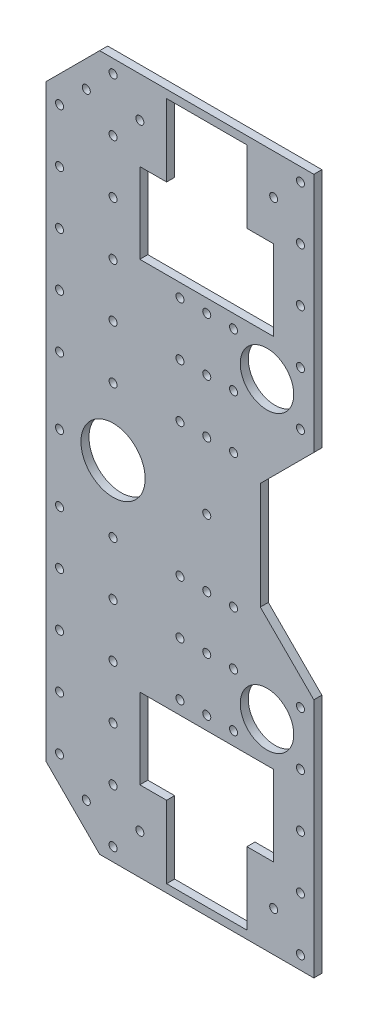
from build123d import *

# Parameters (mm, degrees)
MAIN_DEPTH                    = 3
MOTORCODERLEFTHOLE_DEPTH      = 144.209636547
SKETCH4_R                     = 1.5
BOTTOMLEFTHOLE_DEPTH          = 144.209636547
BOTTOMLEFTHOLELPATTERN_COUNT  = 5
BOTTOMLEFTHOLELPATTERN_PITCH  = 20
SKETCH5_R                     = 1.5
BOTTOMLEFTHOLE2_DEPTH         = 144.209636547
BOTTOMLEFTHOLE2LPATTERN_COUNT = 6
BOTTOMLEFTHOLE2LPATTERN_PITCH = 20
SKETCH6_R                     = 1.5
TOPLEFTHOLE_DEPTH             = 144.209636547
TOPLEFTHOLELPATTERN_COUNT     = 5
TOPLEFTHOLELPATTERN_PITCH     = 20
SKETCH7_R                     = 1.5
MOTORFIXHOLES_DEPTH           = 144.209636547
MOTORFIXHOLELPATTERN_COUNT    = 3
MOTORFIXHOLELPATTERN_PITCH    = 20
SKETCH8_R                     = 1.5
CODERHOLE_DEPTH               = 144.209636547
MIRROR1_COPY_1_SKETCH_R       = 1.5
MIRROR1_COPY_1_DEPTH          = 144.209636547
MIRROR1_COPY_2_SKETCH_R       = 1.5
MIRROR1_COPY_2_DEPTH          = 144.209636547
MIRROR1_COPY_3_SKETCH_R       = 1.5
MIRROR1_COPY_3_DEPTH          = 144.209636547
MIRROR1_COPY_4_SKETCH_R       = 1.5
MIRROR1_COPY_4_DEPTH          = 144.209636547
MIRROR1_COPY_5_SKETCH_R       = 1.5
MIRROR1_COPY_5_DEPTH          = 144.209636547
MIRROR1_COPY_6_SKETCH_R       = 1.5
MIRROR1_COPY_6_DEPTH          = 144.209636547
MIRROR1_COPY_7_SKETCH_R       = 1.5
MIRROR1_COPY_7_DEPTH          = 144.209636547
MIRROR1_COPY_8_SKETCH_R       = 1.5
MIRROR1_COPY_8_DEPTH          = 144.209636547
MIRROR1_COPY_9_SKETCH_R       = 1.5
MIRROR1_COPY_9_DEPTH          = 144.209636547
MIRROR1_COPY_10_SKETCH_R      = 1.5
MIRROR1_COPY_10_DEPTH         = 144.209636547
MIRROR1_COPY_11_SKETCH_R      = 1.5
MIRROR1_COPY_11_DEPTH         = 144.209636547
MIRROR1_COPY_12_SKETCH_R      = 1.5
MIRROR1_COPY_12_DEPTH         = 144.209636547
MIRROR1_COPY_13_SKETCH_R      = 1.5
MIRROR1_COPY_13_DEPTH         = 144.209636547
MIRROR1_COPY_14_SKETCH_R      = 1.5
MIRROR1_COPY_14_DEPTH         = 144.209636547
MIRROR1_COPY_15_SKETCH_R      = 1.5
MIRROR1_COPY_15_DEPTH         = 144.209636547
MIRROR1_COPY_16_SKETCH_R      = 1.5
MIRROR1_COPY_16_DEPTH         = 144.209636547
MIRROR1_COPY_17_SKETCH_R      = 1.5
MIRROR1_COPY_17_DEPTH         = 144.209636547
MIRROR1_COPY_18_SKETCH_R      = 1.5
MIRROR1_COPY_18_DEPTH         = 144.209636547
MIRROR1_COPY_19_SKETCH_R      = 1.5
MIRROR1_COPY_19_DEPTH         = 144.209636547
SKETCH3_R                     = 12
SKETCH3_R_2                   = 10
SKETCH3_R_3                   = 1.5
BIGHOLES_DEPTH                = 144.209636547


with BuildPart() as part:
    # Sketch1 → Main (new body)
    with BuildSketch(Plane.XY):
        Polygon((-60, 110), (-60, -110), (-40, -130), (40, -130), (40, -40), (20, -20), (20, 20), (40, 40), (40, 130), (-40, 130), align=None)
    extrude(amount=MAIN_DEPTH)

    # Sketch2 → MotorCoderLeftHole (cut, through all)
    with BuildSketch(Plane.XY.offset(3)):
        Polygon((-25, 100), (-25, 70), (25, 70), (25, 100), (15, 100), (15, 127), (-15, 127), (-15, 100), align=None)
    motorcoderlefthole = extrude(amount=-MOTORCODERLEFTHOLE_DEPTH, mode=Mode.SUBTRACT)

    # Sketch4 → BottomLeftHole (cut, through all)
    with BuildSketch(Plane.XY.offset(3)):
        with Locations((-55, 105)):
            Circle(SKETCH4_R)
    bottomlefthole = extrude(amount=-BOTTOMLEFTHOLE_DEPTH, mode=Mode.SUBTRACT)

    # BottomLeftHoleLPattern: BottomLeftHole ×5
    with Locations(*[(0, -i * BOTTOMLEFTHOLELPATTERN_PITCH, 0) for i in range(1, BOTTOMLEFTHOLELPATTERN_COUNT)]):
        add(bottomlefthole, mode=Mode.SUBTRACT)

    # Sketch5 → BottomLeftHole2 (cut, through all)
    with BuildSketch(Plane.XY.offset(3)):
        with Locations((-35, 125)):
            Circle(SKETCH5_R)
    bottomlefthole2 = extrude(amount=-BOTTOMLEFTHOLE2_DEPTH, mode=Mode.SUBTRACT)

    # BottomLeftHole2LPattern: BottomLeftHole2 ×6
    with Locations(*[(0, -i * BOTTOMLEFTHOLE2LPATTERN_PITCH, 0) for i in range(1, BOTTOMLEFTHOLE2LPATTERN_COUNT)]):
        add(bottomlefthole2, mode=Mode.SUBTRACT)

    # Sketch6 → TopLeftHole (cut, through all)
    with BuildSketch(Plane.XY.offset(3)):
        with Locations((35, 125)):
            Circle(SKETCH6_R)
    toplefthole = extrude(amount=-TOPLEFTHOLE_DEPTH, mode=Mode.SUBTRACT)

    # TopLeftHoleLPattern: TopLeftHole ×5
    with Locations(*[(0, -i * TOPLEFTHOLELPATTERN_PITCH, 0) for i in range(1, TOPLEFTHOLELPATTERN_COUNT)]):
        add(toplefthole, mode=Mode.SUBTRACT)

    # Sketch7 → MotorFixHoles (cut, through all)
    with BuildSketch(Plane.XY.offset(3)):
        with Locations((0, 65)):
            Circle(SKETCH7_R)
        with Locations((-10, 65)):
            Circle(SKETCH7_R)
        with Locations((10, 65)):
            Circle(SKETCH7_R)
    motorfixholes = extrude(amount=-MOTORFIXHOLES_DEPTH, mode=Mode.SUBTRACT)

    # MotorFixHoleLPattern: MotorFixHoles ×3
    with Locations(*[(0, -i * MOTORFIXHOLELPATTERN_PITCH, 0) for i in range(1, MOTORFIXHOLELPATTERN_COUNT)]):
        add(motorfixholes, mode=Mode.SUBTRACT)

    # Sketch8 → CoderHole (cut, through all)
    with BuildSketch(Plane.XY.offset(3)):
        with Locations((-45, 115)):
            Circle(SKETCH8_R)
        with Locations((-25, 115)):
            Circle(SKETCH8_R)
        with Locations((25, 115)):
            Circle(SKETCH8_R)
    coderhole = extrude(amount=-CODERHOLE_DEPTH, mode=Mode.SUBTRACT)

    # Mirror1: MotorCoderLeftHole, CoderHole across plane
    add(motorcoderlefthole.mirror(Plane.ZX), mode=Mode.SUBTRACT)
    add(coderhole.mirror(Plane.ZX), mode=Mode.SUBTRACT)

    # Mirror1 copy 1 sketch → Mirror1 copy 1 (cut, through all)
    with BuildSketch(Plane(origin=(0, 20, 3), x_dir=(1, 0, 0), z_dir=(0, 0, 1))):
        with Locations((-55, -105)):
            Circle(MIRROR1_COPY_1_SKETCH_R)
    extrude(amount=-MIRROR1_COPY_1_DEPTH, mode=Mode.SUBTRACT)

    # Mirror1 copy 2 sketch → Mirror1 copy 2 (cut, through all)
    with BuildSketch(Plane(origin=(0, 40, 3), x_dir=(1, 0, 0), z_dir=(0, 0, 1))):
        with Locations((-55, -105)):
            Circle(MIRROR1_COPY_2_SKETCH_R)
    extrude(amount=-MIRROR1_COPY_2_DEPTH, mode=Mode.SUBTRACT)

    # Mirror1 copy 3 sketch → Mirror1 copy 3 (cut, through all)
    with BuildSketch(Plane(origin=(0, 60, 3), x_dir=(1, 0, 0), z_dir=(0, 0, 1))):
        with Locations((-55, -105)):
            Circle(MIRROR1_COPY_3_SKETCH_R)
    extrude(amount=-MIRROR1_COPY_3_DEPTH, mode=Mode.SUBTRACT)

    # Mirror1 copy 4 sketch → Mirror1 copy 4 (cut, through all)
    with BuildSketch(Plane(origin=(0, 80, 3), x_dir=(1, 0, 0), z_dir=(0, 0, 1))):
        with Locations((-55, -105)):
            Circle(MIRROR1_COPY_4_SKETCH_R)
    extrude(amount=-MIRROR1_COPY_4_DEPTH, mode=Mode.SUBTRACT)

    # Mirror1 copy 5 sketch → Mirror1 copy 5 (cut, through all)
    with BuildSketch(Plane.XY.offset(3)):
        with Locations((-55, -105)):
            Circle(MIRROR1_COPY_5_SKETCH_R)
    extrude(amount=-MIRROR1_COPY_5_DEPTH, mode=Mode.SUBTRACT)

    # Mirror1 copy 6 sketch → Mirror1 copy 6 (cut, through all)
    with BuildSketch(Plane(origin=(0, 20, 3), x_dir=(1, 0, 0), z_dir=(0, 0, 1))):
        with Locations((-35, -125)):
            Circle(MIRROR1_COPY_6_SKETCH_R)
    extrude(amount=-MIRROR1_COPY_6_DEPTH, mode=Mode.SUBTRACT)

    # Mirror1 copy 7 sketch → Mirror1 copy 7 (cut, through all)
    with BuildSketch(Plane(origin=(0, 40, 3), x_dir=(1, 0, 0), z_dir=(0, 0, 1))):
        with Locations((-35, -125)):
            Circle(MIRROR1_COPY_7_SKETCH_R)
    extrude(amount=-MIRROR1_COPY_7_DEPTH, mode=Mode.SUBTRACT)

    # Mirror1 copy 8 sketch → Mirror1 copy 8 (cut, through all)
    with BuildSketch(Plane(origin=(0, 60, 3), x_dir=(1, 0, 0), z_dir=(0, 0, 1))):
        with Locations((-35, -125)):
            Circle(MIRROR1_COPY_8_SKETCH_R)
    extrude(amount=-MIRROR1_COPY_8_DEPTH, mode=Mode.SUBTRACT)

    # Mirror1 copy 9 sketch → Mirror1 copy 9 (cut, through all)
    with BuildSketch(Plane(origin=(0, 80, 3), x_dir=(1, 0, 0), z_dir=(0, 0, 1))):
        with Locations((-35, -125)):
            Circle(MIRROR1_COPY_9_SKETCH_R)
    extrude(amount=-MIRROR1_COPY_9_DEPTH, mode=Mode.SUBTRACT)

    # Mirror1 copy 10 sketch → Mirror1 copy 10 (cut, through all)
    with BuildSketch(Plane(origin=(0, 100, 3), x_dir=(1, 0, 0), z_dir=(0, 0, 1))):
        with Locations((-35, -125)):
            Circle(MIRROR1_COPY_10_SKETCH_R)
    extrude(amount=-MIRROR1_COPY_10_DEPTH, mode=Mode.SUBTRACT)

    # Mirror1 copy 11 sketch → Mirror1 copy 11 (cut, through all)
    with BuildSketch(Plane.XY.offset(3)):
        with Locations((-35, -125)):
            Circle(MIRROR1_COPY_11_SKETCH_R)
    extrude(amount=-MIRROR1_COPY_11_DEPTH, mode=Mode.SUBTRACT)

    # Mirror1 copy 12 sketch → Mirror1 copy 12 (cut, through all)
    with BuildSketch(Plane(origin=(0, 20, 3), x_dir=(1, 0, 0), z_dir=(0, 0, 1))):
        with Locations((35, -125)):
            Circle(MIRROR1_COPY_12_SKETCH_R)
    extrude(amount=-MIRROR1_COPY_12_DEPTH, mode=Mode.SUBTRACT)

    # Mirror1 copy 13 sketch → Mirror1 copy 13 (cut, through all)
    with BuildSketch(Plane(origin=(0, 40, 3), x_dir=(1, 0, 0), z_dir=(0, 0, 1))):
        with Locations((35, -125)):
            Circle(MIRROR1_COPY_13_SKETCH_R)
    extrude(amount=-MIRROR1_COPY_13_DEPTH, mode=Mode.SUBTRACT)

    # Mirror1 copy 14 sketch → Mirror1 copy 14 (cut, through all)
    with BuildSketch(Plane(origin=(0, 60, 3), x_dir=(1, 0, 0), z_dir=(0, 0, 1))):
        with Locations((35, -125)):
            Circle(MIRROR1_COPY_14_SKETCH_R)
    extrude(amount=-MIRROR1_COPY_14_DEPTH, mode=Mode.SUBTRACT)

    # Mirror1 copy 15 sketch → Mirror1 copy 15 (cut, through all)
    with BuildSketch(Plane(origin=(0, 80, 3), x_dir=(1, 0, 0), z_dir=(0, 0, 1))):
        with Locations((35, -125)):
            Circle(MIRROR1_COPY_15_SKETCH_R)
    extrude(amount=-MIRROR1_COPY_15_DEPTH, mode=Mode.SUBTRACT)

    # Mirror1 copy 16 sketch → Mirror1 copy 16 (cut, through all)
    with BuildSketch(Plane.XY.offset(3)):
        with Locations((35, -125)):
            Circle(MIRROR1_COPY_16_SKETCH_R)
    extrude(amount=-MIRROR1_COPY_16_DEPTH, mode=Mode.SUBTRACT)

    # Mirror1 copy 17 sketch → Mirror1 copy 17 (cut, through all)
    with BuildSketch(Plane(origin=(0, 20, 3), x_dir=(1, 0, 0), z_dir=(0, 0, 1))):
        with Locations((0, -65)):
            Circle(MIRROR1_COPY_17_SKETCH_R)
        with Locations((-10, -65)):
            Circle(MIRROR1_COPY_17_SKETCH_R)
        with Locations((10, -65)):
            Circle(MIRROR1_COPY_17_SKETCH_R)
    extrude(amount=-MIRROR1_COPY_17_DEPTH, mode=Mode.SUBTRACT)

    # Mirror1 copy 18 sketch → Mirror1 copy 18 (cut, through all)
    with BuildSketch(Plane(origin=(0, 40, 3), x_dir=(1, 0, 0), z_dir=(0, 0, 1))):
        with Locations((0, -65)):
            Circle(MIRROR1_COPY_18_SKETCH_R)
        with Locations((-10, -65)):
            Circle(MIRROR1_COPY_18_SKETCH_R)
        with Locations((10, -65)):
            Circle(MIRROR1_COPY_18_SKETCH_R)
    extrude(amount=-MIRROR1_COPY_18_DEPTH, mode=Mode.SUBTRACT)

    # Mirror1 copy 19 sketch → Mirror1 copy 19 (cut, through all)
    with BuildSketch(Plane.XY.offset(3)):
        with Locations((0, -65)):
            Circle(MIRROR1_COPY_19_SKETCH_R)
        with Locations((-10, -65)):
            Circle(MIRROR1_COPY_19_SKETCH_R)
        with Locations((10, -65)):
            Circle(MIRROR1_COPY_19_SKETCH_R)
    extrude(amount=-MIRROR1_COPY_19_DEPTH, mode=Mode.SUBTRACT)

    # Sketch3 → BigHoles (cut, through all)
    with BuildSketch(Plane.XY.offset(3)):
        with Locations((-35, 0)):
            Circle(SKETCH3_R)
        with Locations((22.5, 55)):
            Circle(SKETCH3_R_2)
        with Locations((22.5, -55)):
            Circle(SKETCH3_R_2)
        Circle(SKETCH3_R_3)
        with Locations((-55, 0)):
            Circle(SKETCH3_R_3)
    extrude(amount=-BIGHOLES_DEPTH, mode=Mode.SUBTRACT)


solid = part.part
